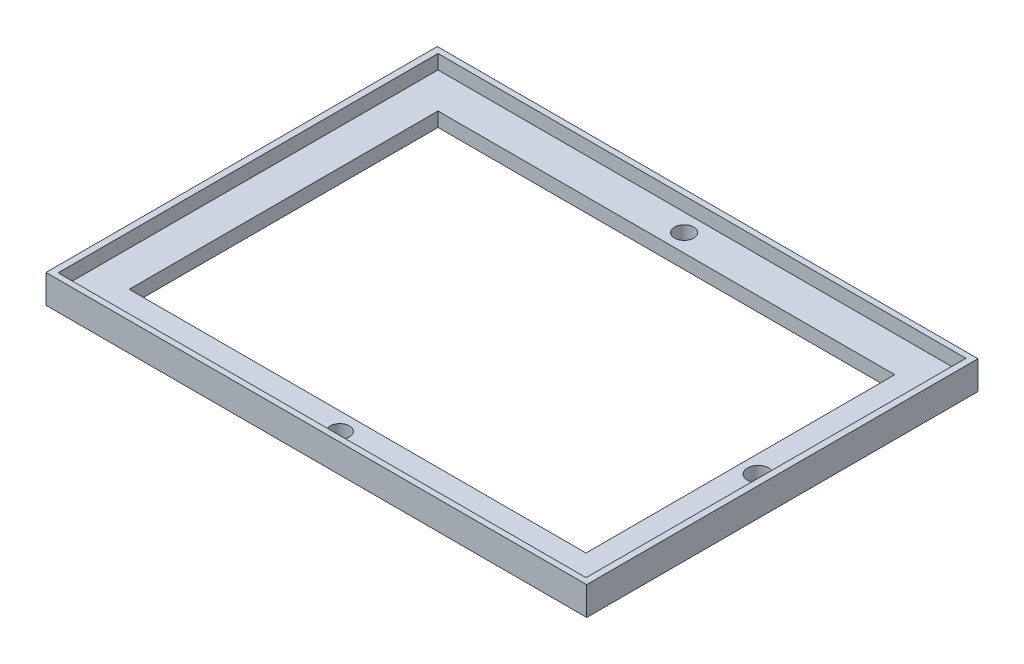
from build123d import *

# Parameters (mm, degrees)
SKETCH1_W           = 76
SKETCH1_H           = 55
SKETCH1_W_2         = 64.2
SKETCH1_H_2         = 43.4
BOSS_EXTRUDE1_DEPTH = 4
SKETCH2_W           = 74.2
SKETCH2_H           = 53.4
CUT_EXTRUDE1_DEPTH  = 2
SKETCH3_R           = 1.35
CUT_EXTRUDE2_DEPTH  = 2
CUT_EXTRUDE3_REACH  = 4
SKETCH4_R           = 1.5


with BuildPart() as part:
    # Sketch1 → Boss-Extrude1 (new body)
    with BuildSketch(Plane(origin=(0, 0, 0), x_dir=(1, 0, 0), z_dir=(0, 1, 0))):
        Rectangle(SKETCH1_W, SKETCH1_H)
        Rectangle(SKETCH1_W_2, SKETCH1_H_2, mode=Mode.SUBTRACT)
    extrude(amount=BOSS_EXTRUDE1_DEPTH)

    # Sketch2 → Cut-Extrude1 (cut)
    with BuildSketch(Plane(origin=(0, 4, 0), x_dir=(1, 0, 0), z_dir=(0, 1, 0))):
        Rectangle(SKETCH2_W, SKETCH2_H)
    extrude(amount=-CUT_EXTRUDE1_DEPTH, mode=Mode.SUBTRACT)

    # Sketch3 → Cut-Extrude2 (cut)
    with BuildSketch(Plane(origin=(0, 2, 0), x_dir=(1, 0, 0), z_dir=(0, 1, 0))):
        with Locations((0, 24.2)):
            Circle(SKETCH3_R)
        with Locations((0, -24.2)):
            Circle(SKETCH3_R)
    extrude(amount=-CUT_EXTRUDE2_DEPTH, mode=Mode.SUBTRACT)

    # Sketch4 → Cut-Extrude3 (cut, up to next)
    with BuildSketch(Plane(origin=(0, 2, 0), x_dir=(1, 0, 0), z_dir=(0, 1, 0)), mode=Mode.PRIVATE) as cut_extrude3_sk1:
        with Locations((34.6, 0)):
            Circle(SKETCH4_R)
    cut_extrude3_tool1 = extrude(cut_extrude3_sk1.sketch, amount=-CUT_EXTRUDE3_REACH, mode=Mode.PRIVATE) & part.part
    add(cut_extrude3_tool1.solids().sort_by_distance((34.6, 2, 0))[0], mode=Mode.SUBTRACT)


solid = part.part
